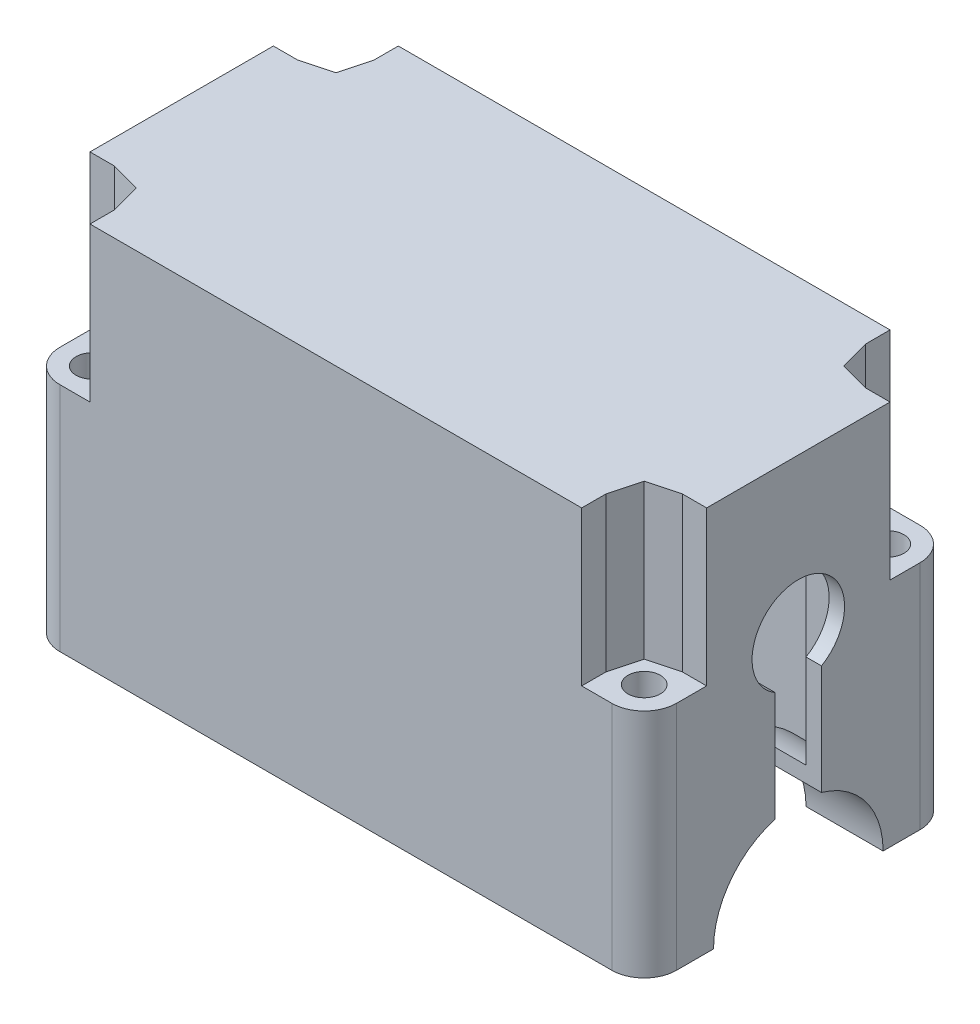
from build123d import *

# Parameters (mm, degrees)
ESQUISSE1_W             = 80
ESQUISSE1_H             = 40
BOSS_EXTRU_1_DEPTH      = 50
ENL_V_MAT_EXTRU_1_DEPTH = 78
ESQUISSE3_W             = 2
ESQUISSE3_H             = 50
BOSS_EXTRU_2_DEPTH      = 40
ESQUISSE4_R             = 11
ENL_V_MAT_EXTRU_2_DEPTH = 81
ESQUISSE5_W             = 60
ESQUISSE5_H             = 36
ENL_V_MAT_EXTRU_3_DEPTH = 48
ESQUISSE6_W             = 10
ESQUISSE6_H             = 5
ENL_V_MAT_EXTRU_4_DEPTH = 2
ENL_V_MAT_EXTRU_5_DEPTH = 10
ESQUISSE8_W             = 10
ESQUISSE8_H             = 9
BOSS_EXTRU_3_DEPTH      = 50
ESQUISSE9_R             = 2.1
ENL_V_MAT_EXTRU_6_DEPTH = 51
ESQUISSE10_R            = 2.1
ENL_V_MAT_EXTRU_7_DEPTH = 20
CONG_1_R                = 4.2
ESQUISSE11_W            = 2
ESQUISSE11_H            = 5
ESQUISSE11_W_2          = 7
ESQUISSE11_H_2          = 2
BOSS_EXTRU_4_DEPTH      = 5


with BuildPart() as part:
    # Esquisse1 → Boss.-Extru.1 (new body)
    with BuildSketch(Plane(origin=(0, 0, 0), x_dir=(1, 0, 0), z_dir=(0, 1, 0))):
        with Locations((40, 20)):
            Rectangle(ESQUISSE1_W, ESQUISSE1_H)
    extrude(amount=BOSS_EXTRU_1_DEPTH)

    # Esquisse2 → Enlèv. mat.-Extru.1 (cut)
    with BuildSketch(Plane.ZY):
        with BuildLine():
            Line((-2, 48), (-38, 48))
            Line((-38, 48), (-38, 2))
            Line((-38, 2), (-32.845232579, 2))
            ThreePointArc((-32.845232579, 2), (-20, 13), (-7.154767421, 2))
            Line((-7.154767421, 2), (-2, 2))
            Line((-2, 2), (-2, 48))
        make_face()
    extrude(amount=-ENL_V_MAT_EXTRU_1_DEPTH, mode=Mode.SUBTRACT)

    # Esquisse3 → Boss.-Extru.2 (add)
    with BuildSketch(Plane(origin=(0, 0, -40), x_dir=(-1, 0, 0), z_dir=(0, 0, -1))):
        with Locations((-1, 25)):
            Rectangle(ESQUISSE3_W, ESQUISSE3_H)
    extrude(amount=-BOSS_EXTRU_2_DEPTH)

    # Esquisse4 → Enlèv. mat.-Extru.2 (cut, through all)
    with BuildSketch(Plane.ZY):
        with Locations((-20, 0)):
            Circle(ESQUISSE4_R)
    extrude(amount=-ENL_V_MAT_EXTRU_2_DEPTH, mode=Mode.SUBTRACT)

    # Esquisse5 → Enlèv. mat.-Extru.3 (cut)
    with BuildSketch(Plane.XZ):
        with Locations((40, -20)):
            Rectangle(ESQUISSE5_W, ESQUISSE5_H)
    extrude(amount=-ENL_V_MAT_EXTRU_3_DEPTH, mode=Mode.SUBTRACT)

    # Esquisse6 → Enlèv. mat.-Extru.4 (cut)
    with BuildSketch(Plane.ZY):
        with Locations((-20, 40.5)):
            Rectangle(ESQUISSE6_W, ESQUISSE6_H)
    extrude(amount=-ENL_V_MAT_EXTRU_4_DEPTH, mode=Mode.SUBTRACT)

    # Esquisse7 → Enlèv. mat.-Extru.5 (cut)
    with BuildSketch(Plane(origin=(80, 0, 0), x_dir=(0, 0, -1), z_dir=(1, 0, 0))):
        with BuildLine():
            Line((17, 24.803847577), (17, 27.021710026))
            Line((17, 27.021710026), (23, 27.021710026))
            Line((23, 27.021710026), (23, 24.803847577))
            ThreePointArc((23, 24.803847577), (25.196152423, 27), (26, 30))
            ThreePointArc((26, 30), (17, 35.196152423), (17, 24.803847577))
        make_face()
        with BuildLine():
            Line((23, 27.021710026), (17, 27.021710026))
            Line((17, 27.021710026), (17, 24.803847577))
            ThreePointArc((17, 24.803847577), (20, 24), (23, 24.803847577))
            Line((23, 24.803847577), (23, 27.021710026))
        make_face()
        with BuildLine():
            ThreePointArc((23, 24.803847577), (20, 24), (17, 24.803847577))
            Line((17, 24.803847577), (17, 10.583005244))
            ThreePointArc((17, 10.583005244), (20, 11), (23, 10.583005244))
            Line((23, 10.583005244), (23, 24.803847577))
        make_face()
    extrude(amount=-ENL_V_MAT_EXTRU_5_DEPTH, mode=Mode.SUBTRACT)

    # Esquisse8 → Boss.-Extru.3 (add)
    with BuildSketch(Plane(origin=(0, 50, 0), x_dir=(1, 0, 0), z_dir=(0, 1, 0))):
        with Locations((5, 4.5)):
            Rectangle(ESQUISSE8_W, ESQUISSE8_H)
        with Locations((5, 35.5)):
            Rectangle(ESQUISSE8_W, ESQUISSE8_H)
        with Locations((75, 35.5)):
            Rectangle(ESQUISSE8_W, ESQUISSE8_H)
        with Locations((75, 4.5)):
            Rectangle(ESQUISSE8_W, ESQUISSE8_H)
    extrude(amount=-BOSS_EXTRU_3_DEPTH)

    # Esquisse9 → Enlèv. mat.-Extru.6 (cut, through all)
    with BuildSketch(Plane(origin=(0, 50, 0), x_dir=(1, 0, 0), z_dir=(0, 1, 0))):
        with Locations((75.8, 4.2)):
            Circle(ESQUISSE9_R)
        with Locations((4.2, 4.2)):
            Circle(ESQUISSE9_R)
        with Locations((4.2, 35.8)):
            Circle(ESQUISSE9_R)
        with Locations((75.8, 35.8)):
            Circle(ESQUISSE9_R)
    extrude(amount=-ENL_V_MAT_EXTRU_6_DEPTH, mode=Mode.SUBTRACT)

    # Esquisse10 → Enlèv. mat.-Extru.7 (cut)
    with BuildSketch(Plane(origin=(0, 50, 0), x_dir=(1, 0, 0), z_dir=(0, 1, 0))):
        Polygon((5.246004718, 39.703742751), (8.103742751, 36.846004718), (8.103742751, 40), (0, 40), (0, 31.896257249), (3.153995282, 31.896257249), (0.296257249, 34.753995282), (1.342261967, 38.657738033), align=None)
        Polygon((7.057738033, 32.942261967), (8.103742751, 36.846004718), (5.246004718, 39.703742751), (1.342261967, 38.657738033), (0.296257249, 34.753995282), (3.153995282, 31.896257249), align=None)
        with Locations((4.2, 35.8)):
            Circle(ESQUISSE10_R, mode=Mode.SUBTRACT)
        Polygon((0.296257249, 5.246004718), (1.342261967, 1.342261967), (5.246004718, 0.296257249), (8.103742751, 3.153995282), (7.057738033, 7.057738033), (3.153995282, 8.103742751), align=None)
        with Locations((4.2, 4.2)):
            Circle(ESQUISSE10_R, mode=Mode.SUBTRACT)
        Polygon((3.153995282, 8.103742751), (0, 8.103742751), (0, 0), (8.103742751, 0), (8.103742751, 3.153995282), (5.246004718, 0.296257249), (1.342261967, 1.342261967), (0.296257249, 5.246004718), align=None)
        Polygon((80, 0), (80, 8.103742751), (76.846004718, 8.103742751), (79.703742751, 5.246004718), (78.657738033, 1.342261967), (74.753995282, 0.296257249), (71.896257249, 3.153995282), (71.896257249, 0), align=None)
        Polygon((72.942261967, 7.057738033), (71.896257249, 3.153995282), (74.753995282, 0.296257249), (78.657738033, 1.342261967), (79.703742751, 5.246004718), (76.846004718, 8.103742751), align=None)
        with Locations((75.8, 4.2)):
            Circle(ESQUISSE10_R, mode=Mode.SUBTRACT)
        Polygon((80, 40), (71.896257249, 40), (71.896257249, 36.846004718), (74.753995282, 39.703742751), (78.657738033, 38.657738033), (79.703742751, 34.753995282), (76.846004718, 31.896257249), (80, 31.896257249), align=None)
        Polygon((74.753995282, 39.703742751), (71.896257249, 36.846004718), (72.942261967, 32.942261967), (76.846004718, 31.896257249), (79.703742751, 34.753995282), (78.657738033, 38.657738033), align=None)
        with Locations((75.8, 35.8)):
            Circle(ESQUISSE10_R, mode=Mode.SUBTRACT)
    extrude(amount=-ENL_V_MAT_EXTRU_7_DEPTH, mode=Mode.SUBTRACT)

    # Congé1
    cong_1_edges = [part.edges().sort_by_distance(p)[0] for p in [
        (0, 15, -40),
        (0, 15, 0),
        (80, 15, 0),
        (80, 15, -40),
    ]]
    fillet(cong_1_edges, radius=CONG_1_R)

    # Esquisse11 → Boss.-Extru.4 (add)
    with BuildSketch(Plane.XZ.offset(-48)):
        with Locations((46, -13.5)):
            Rectangle(ESQUISSE11_W, ESQUISSE11_H)
        Polygon((40, -11), (45, -11), (47, -11), (47, -9), (40, -9), align=None)
        with Locations((46, -26.5)):
            Rectangle(ESQUISSE11_W, ESQUISSE11_H)
        with Locations((43.5, -30)):
            Rectangle(ESQUISSE11_W_2, ESQUISSE11_H_2)
    extrude(amount=BOSS_EXTRU_4_DEPTH)


solid = part.part
